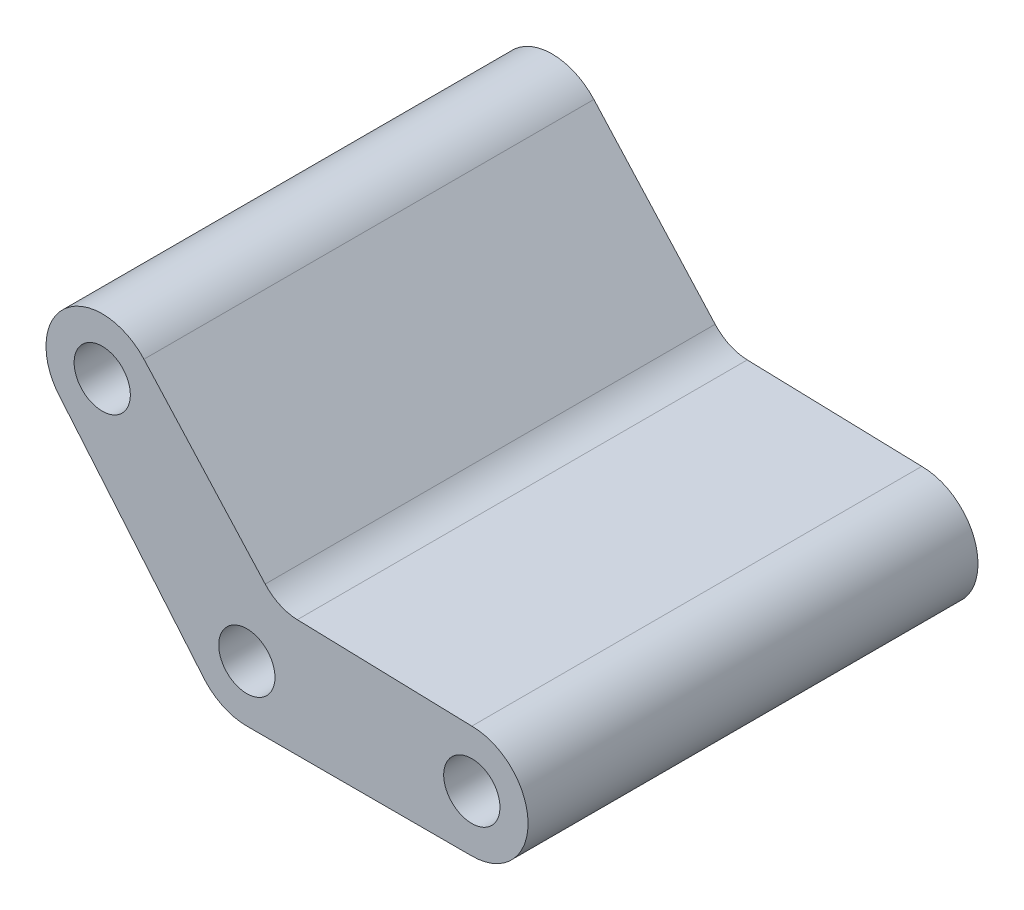
from build123d import *

# Parameters (mm, degrees)
SKETCH2_R           = 25
BOSS_EXTRUDE1_DEPTH = 400


with BuildPart() as part:
    # Sketch2 → Boss-Extrude1 (new body)
    with BuildSketch(Plane.XY):
        with BuildLine():
            ThreePointArc((16.315934256, 67.533788123), (29.24063231, 58.034577093), (44.858014963, 54.37668302))
            Line((44.858014963, 54.37668302), (200, 50))
            ThreePointArc((200, 50), (250, 0), (200, -50))
            Line((200, -50), (0, -50))
            ThreePointArc((0, -50), (-20.289323408, -45.698395548), (-37.08758106, -33.533734226))
            Line((-37.08758106, -33.533734226), (-165.645102997, 119.675154398))
            ThreePointArc((-165.645102997, 119.675154398), (-162.091256163, 190.296469684), (-91.469940878, 186.74262285))
            Line((-91.469940878, 186.74262285), (16.315934256, 67.533788123))
        make_face()
        with Locations((200, 0)):
            Circle(SKETCH2_R, mode=Mode.SUBTRACT)
        Circle(SKETCH2_R, mode=Mode.SUBTRACT)
        with Locations((-128.557521937, 153.208888624)):
            Circle(SKETCH2_R, mode=Mode.SUBTRACT)
    extrude(amount=BOSS_EXTRUDE1_DEPTH)


solid = part.part
